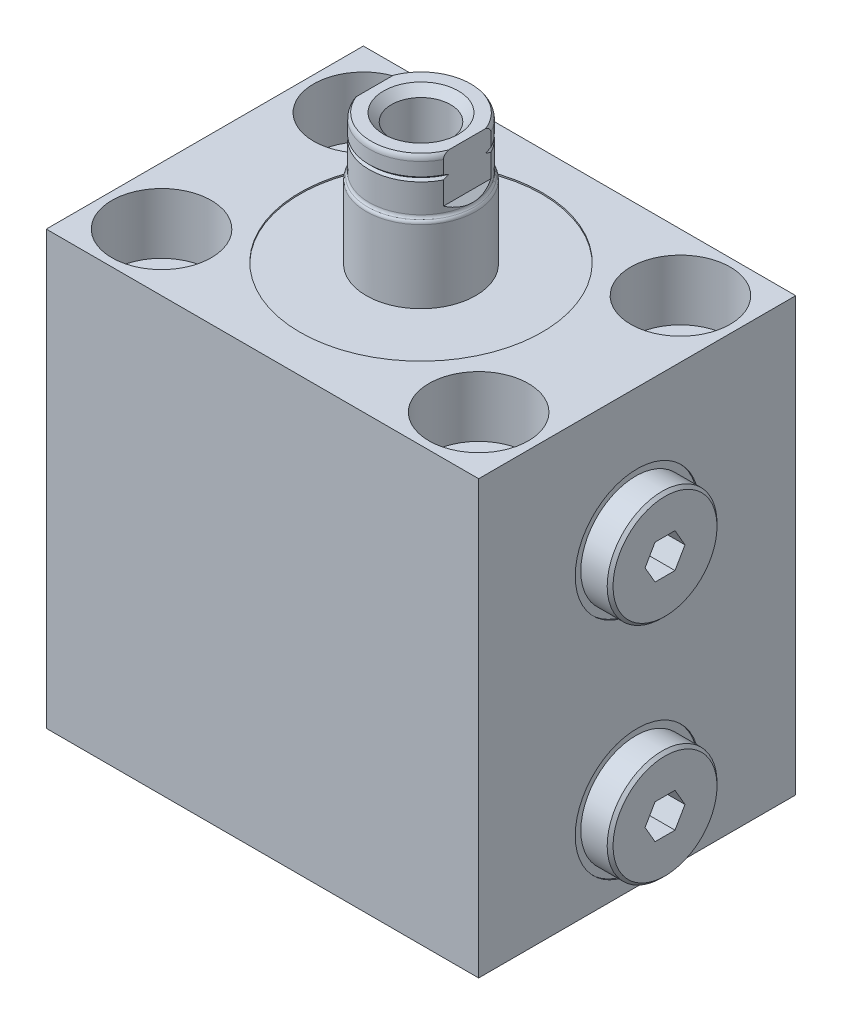
from build123d import *

# Parameters (mm, degrees)
SKETCH1_W                  = 75
SKETCH1_H                  = 55
EXTRUDE1_DEPTH             = 75
SKETCH2_R                  = 21
CUT_EXTRUDE1_DEPTH         = 0.254
CHAMFER1_SIZE              = 0.508
CUT_EXTRUDE2_DEPTH         = 5.9944
LPATTERN1_COUNT            = 2
LPATTERN1_PITCH            = 39
CHAMFER1_OF_LPATTERN1_SIZE = 0.508
SKETCH7_R                  = 0.889
LPATTERN2_COUNT            = 2
LPATTERN2_PITCH            = 27.5
CUT_EXTRUDE3_DEPTH         = 28.5
CUT_EXTRUDE3_DEPTH_BACK    = 28.5
HOLE1_D                    = 10.49
HOLE1_CBORE_D              = 17.247
HOLE1_CBORE_DEPTH          = 10.49


with BuildPart() as part:
    # Sketch1 → Extrude1 (new body)
    with BuildSketch(Plane(origin=(0, 0, 0), x_dir=(1, 0, 0), z_dir=(0, 1, 0))):
        Rectangle(SKETCH1_W, SKETCH1_H)
    extrude(amount=EXTRUDE1_DEPTH)

    # Sketch2 → Cut-Extrude1 (cut)
    with BuildSketch(Plane(origin=(0, 75, 0), x_dir=(1, 0, 0), z_dir=(0, 1, 0))):
        with Locations(Location((0, 0, 0), (0, 0, 270))):  # turned: the seam where the file's is
            Circle(SKETCH2_R)
    extrude(amount=-CUT_EXTRUDE1_DEPTH, mode=Mode.SUBTRACT)

    # Sketch3 → Cut-Revolve1 (revolve, cut)
    with BuildSketch(Plane.XY, mode=Mode.PRIVATE) as cut_revolve1_sk:
        Polygon((37.5, 52), (37.5, 41.256), (37.246, 41.256), (37.246, 45.3452), (36.5348, 46.0564), (21.752, 46.0564), (21.752, 52), align=None)
    cut_revolve1 = revolve(cut_revolve1_sk.sketch.rotate(Axis((-6.847979502, 52, 0), (1, 0, 0)), 270), axis=Axis((-6.847979502, 52, 0), (1, 0, 0)), mode=Mode.SUBTRACT)  # turned: the seam where the file's is

    # Sketch4 → Revolve1 (revolve)
    with BuildSketch(Plane.XY, mode=Mode.PRIVATE) as revolve1_sk:
        Polygon((25.308, 52), (25.308, 57.9182), (37.246, 57.9182), (37.246, 61.525), (42.326, 61.525), (42.326, 52), align=None)
    revolve1 = revolve(revolve1_sk.sketch.rotate(Axis((8.732572807, 52, 0), (1, 0, 0)), 90), axis=Axis((8.732572807, 52, 0), (1, 0, 0)))  # turned: the seam where the file's is

    # Chamfer1
    chamfer1_edges = [part.edges().sort_by_distance(p)[0] for p in [
        (42.326, 52, -9.525),
    ]]
    chamfer(chamfer1_edges, length=CHAMFER1_SIZE)

    # Sketch5 → Cut-Extrude2 (cut)
    with BuildSketch(Plane(origin=(42.326, 0, 0), x_dir=(0, 0, -1), z_dir=(1, 0, 0))):
        Polygon((1.730434227, 54.9972), (-1.730434227, 54.9972), (-3.460868454, 52), (-1.730434227, 49.0028), (1.730434227, 49.0028), (3.460868454, 52), align=None)
    cut_extrude2 = extrude(amount=-CUT_EXTRUDE2_DEPTH, mode=Mode.SUBTRACT)

    # LPattern1: Cut-Revolve1, Revolve1, Cut-Extrude2 ×2
    with Locations(*[(0, -i * LPATTERN1_PITCH, 0) for i in range(1, LPATTERN1_COUNT)]):
        add(cut_revolve1, mode=Mode.SUBTRACT)
        add(revolve1)
        add(cut_extrude2, mode=Mode.SUBTRACT)

    # Chamfer1 of LPattern1
    chamfer1_of_lpattern1_edges = [part.edges().sort_by_distance(p)[0] for p in [
        (42.326, 13, -9.525),
    ]]
    chamfer(chamfer1_of_lpattern1_edges, length=CHAMFER1_OF_LPATTERN1_SIZE)

    # Sketch6 → Cut-Revolve2 (revolve, cut)
    with BuildSketch(Plane.XY, mode=Mode.PRIVATE) as cut_revolve2_sk:
        Polygon((0, 0), (0, 14.895831126), (1.2446, 14.148), (1.2446, 4.9529), (1.7525, 4.445), (3.2512, 4.445), (3.2512, 1.448), (5.7025, 1.448), (5.7025, 0), align=None)
    cut_revolve2 = revolve(cut_revolve2_sk.sketch.rotate(Axis((0, 0, 0), (0, 1, 0)), 90), axis=Axis((0, 0, 0), (0, 1, 0)), mode=Mode.SUBTRACT)  # turned: the seam where the file's is

    # Sketch7 → Revolve3 (revolve)
    with BuildSketch(Plane.XY, mode=Mode.PRIVATE) as revolve3_sk:
        with Locations((4.814, 0.5844)):
            Circle(SKETCH7_R)
    revolve3 = revolve(revolve3_sk.sketch.rotate(Axis((0, 0, 0), (0, 1, 0)), 90), axis=Axis((0, 0, 0), (0, 1, 0)))  # turned: the seam where the file's is

    # LPattern2: Cut-Revolve2, Revolve3 ×2
    with Locations(*[(-i * LPATTERN2_PITCH, 0, 0) for i in range(1, LPATTERN2_COUNT)]):
        add(cut_revolve2, mode=Mode.SUBTRACT)
        add(revolve3)

    # Sketch8 → Revolve4 (revolve)
    with BuildSketch(Plane.XY, mode=Mode.PRIVATE) as revolve4_sk:
        with BuildLine():
            Line((9.5, 74.746), (9.5, 87.371283915))
            ThreePointArc((9.5, 87.371283915), (9.434702232, 87.679909902), (9.25, 87.935641958))
            ThreePointArc((9.25, 87.935641958), (9.065297768, 88.191374013), (9, 88.5))
            Line((9, 88.5), (9, 96.5094))
            ThreePointArc((9, 96.5094), (8.905612002, 97.037401443), (8.634139733, 97.5))
            Line((8.634139733, 97.5), (0, 97.5))
            Line((0, 97.5), (0, 74.746))
            Line((0, 74.746), (9.5, 74.746))
        make_face()
    revolve(revolve4_sk.sketch.rotate(Axis((0, 0, 0), (0, 1, 0)), 90), axis=Axis((0, 0, 0), (0, 1, 0)))  # turned: the seam where the file's is

    # Sketch10 → Cut-Revolve3 (revolve, cut)
    with BuildSketch(Plane.XY):
        Polygon((6.5, 97.5), (5.131, 96.131), (5.131, 77.18), (0, 74.096984164), (0, 97.5), align=None)
    revolve(axis=Axis((0, 97.5, 0), (0, -1, 0)), mode=Mode.SUBTRACT)

    # Sketch11 → Cut-Revolve4 (revolve, cut)
    with BuildSketch(Plane.XY, mode=Mode.PRIVATE) as cut_revolve4_sk:
        Polygon((9, 94.198), (8.619, 93.817), (9, 93.436), align=None)
    revolve(cut_revolve4_sk.sketch.rotate(Axis((0, 0, 0), (0, 1, 0)), 90), axis=Axis((0, 0, 0), (0, 1, 0)), mode=Mode.SUBTRACT)  # turned: the seam where the file's is

    # Sketch12 → Cut-Extrude3 (cut, two sides)
    with BuildSketch(Plane.XY) as cut_extrude3_sk:
        Polygon((8, 97.5), (8, 89.5), (9.5, 88), (9.5, 97.5), align=None)
        Polygon((-9.5, 97.5), (-8, 97.5), (-8, 89.5), (-9.5, 88), align=None)
    extrude(amount=CUT_EXTRUDE3_DEPTH, mode=Mode.SUBTRACT)
    extrude(cut_extrude3_sk.sketch, amount=-CUT_EXTRUDE3_DEPTH_BACK, mode=Mode.SUBTRACT)

    # Hole1 (through all)
    with Locations(Plane(origin=(0, 75, 0), x_dir=(-1, 0, 0), z_dir=(0, 1, 0))):
        with Locations((27.5, 17.5), (27.5, -17.5), (-27.5, -17.5), (-27.5, 17.5)):
            CounterBoreHole(HOLE1_D / 2, HOLE1_CBORE_D / 2, HOLE1_CBORE_DEPTH)


solid = part.part
